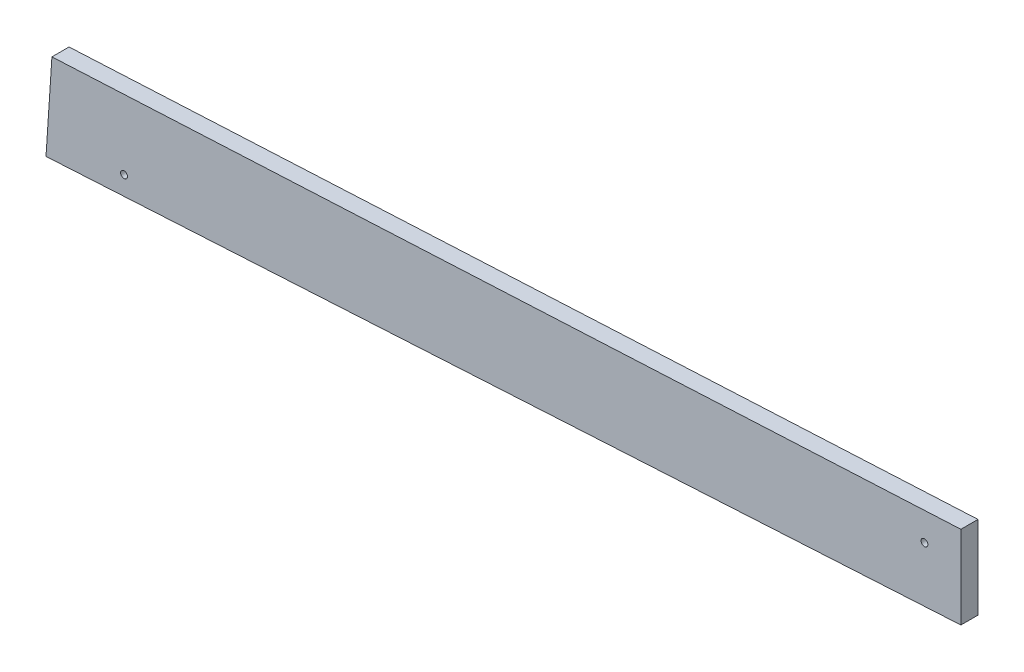
from build123d import *

# Parameters (mm, degrees)
SKETCH1_R           = 0.635
BOSS_EXTRUDE1_DEPTH = 3.175


with BuildPart() as part:
    # Sketch1 → Boss-Extrude1 (new body)
    with BuildSketch(Plane.XY):
        Polygon((-1.5875, 113.111399164), (-1.5875, 128.504233601), (-170.312713847, 120.085477895), (-171.411810426, 103.527545161), align=None)
        with Locations((-156.924194119, 107.841267283)):
            Circle(SKETCH1_R, mode=Mode.SUBTRACT)
        with Locations((-8.346623216, 122.968890993)):
            Circle(SKETCH1_R, mode=Mode.SUBTRACT)
    extrude(amount=-BOSS_EXTRUDE1_DEPTH)


solid = part.part
